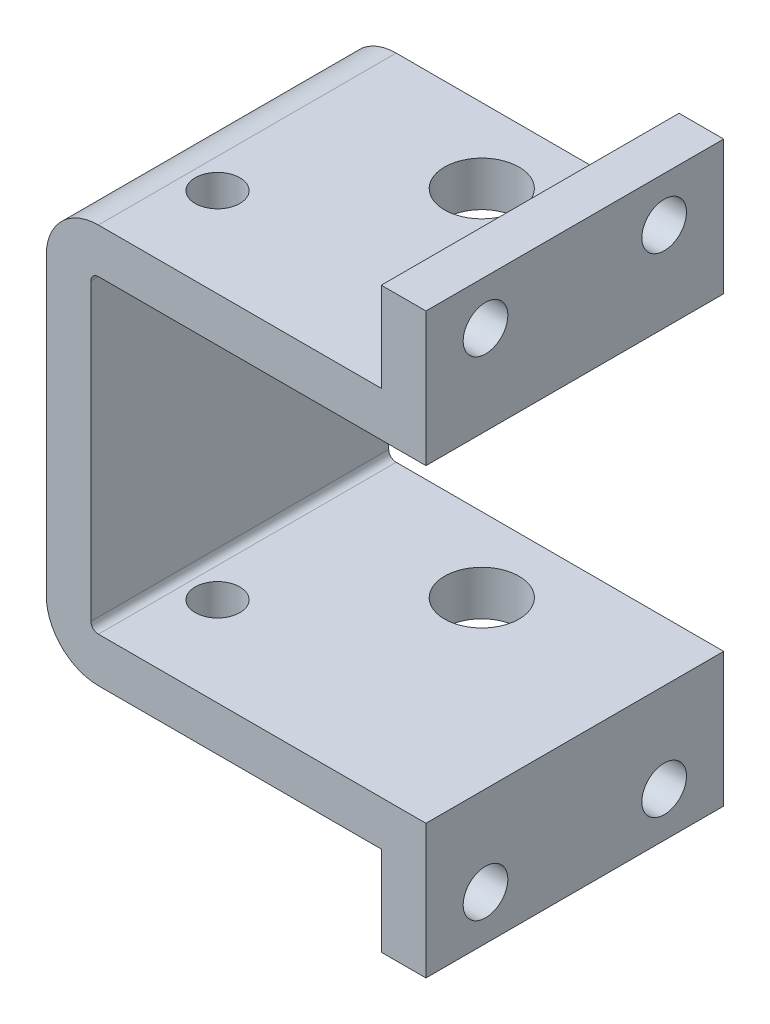
from build123d import *

# Parameters (mm, degrees)
BOSS_EXTRUDE1_DEPTH = 20
SKETCH2_R           = 1.5
SKETCH2_R_2         = 2.5
CUT_EXTRUDE1_DEPTH  = 27
SKETCH3_R           = 1.5
CUT_EXTRUDE2_DEPTH  = 27


with BuildPart() as part:
    # Sketch1 → Boss-Extrude1 (new body)
    with BuildSketch(Plane.XY):
        with BuildLine():
            Line((-1.016707819, -10.4), (20.983292181, -10.4))
            Line((20.983292181, -10.4), (20.983292181, -19.4))
            Line((20.983292181, -19.4), (17.983292181, -19.4))
            Line((17.983292181, -19.4), (17.983292181, -13.4))
            Line((17.983292181, -13.4), (-1.016707819, -13.4))
            ThreePointArc((-1.016707819, -13.4), (-3.491581553, -12.374873734), (-4.516707819, -9.9))
            Line((-4.516707819, -9.9), (-4.516707819, 9.9))
            ThreePointArc((-4.516707819, 9.9), (-3.491581553, 12.374873734), (-1.016707819, 13.4))
            Line((-1.016707819, 13.4), (17.983292181, 13.4))
            Line((17.983292181, 13.4), (17.983292181, 19.4))
            Line((17.983292181, 19.4), (20.983292181, 19.4))
            Line((20.983292181, 19.4), (20.983292181, 10.4))
            Line((20.983292181, 10.4), (-1.016707819, 10.4))
            ThreePointArc((-1.016707819, 10.4), (-1.370261209, 10.253553391), (-1.516707819, 9.9))
            Line((-1.516707819, 9.9), (-1.516707819, -9.9))
            ThreePointArc((-1.516707819, -9.9), (-1.370261209, -10.253553391), (-1.016707819, -10.4))
        make_face()
    extrude(amount=BOSS_EXTRUDE1_DEPTH)

    # Sketch2 → Cut-Extrude1 (cut)
    with BuildSketch(Plane(origin=(0, 13.4, 0), x_dir=(1, 0, 0), z_dir=(0, 1, 0))):
        with Locations((0.983292181, -14)):
            Circle(SKETCH2_R)
        with Locations((9.733292181, -5)):
            Circle(SKETCH2_R_2)
    extrude(amount=-CUT_EXTRUDE1_DEPTH, mode=Mode.SUBTRACT)

    # Sketch3 → Cut-Extrude2 (cut)
    with BuildSketch(Plane.ZY.offset(-17.983292181)):
        with Locations((16, 16.4)):
            Circle(SKETCH3_R)
        with Locations((4, 16.4)):
            Circle(SKETCH3_R)
        with Locations((4, -16.4)):
            Circle(SKETCH3_R)
        with Locations((16, -16.4)):
            Circle(SKETCH3_R)
    extrude(amount=-CUT_EXTRUDE2_DEPTH, mode=Mode.SUBTRACT)


solid = part.part
